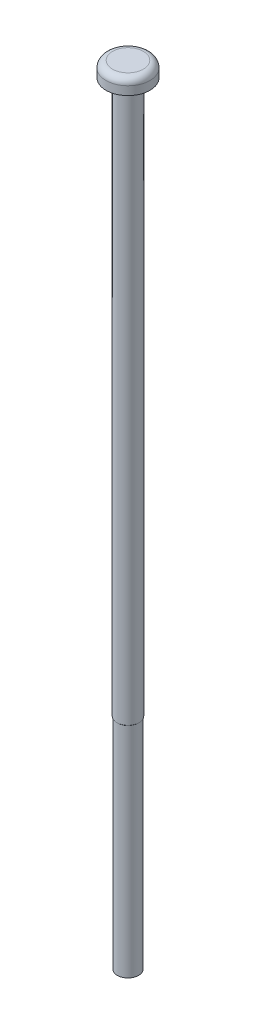
from build123d import *


with BuildPart() as part:
    # Croquis1 → Revolución1 (revolve)
    with BuildSketch(Plane.XY):
        with BuildLine():
            Line((0, 120), (0, 0))
            Line((0, 0), (-1.629604709, 0))
            Line((-1.629604709, 0), (-1.629604709, 33.329604709))
            Line((-1.629604709, 33.329604709), (-1.7, 33.4))
            Line((-1.7, 33.4), (-1.7, 117.7))
            Line((-1.7, 117.7), (-3.35, 117.7))
            Line((-3.35, 117.7), (-3.35, 119))
            ThreePointArc((-3.35, 119), (-3.057106781, 119.707106781), (-2.35, 120))
            Line((-2.35, 120), (0, 120))
        make_face()
    revolve(axis=Axis((0, 120, 0), (0, -1, 0)))


solid = part.part
